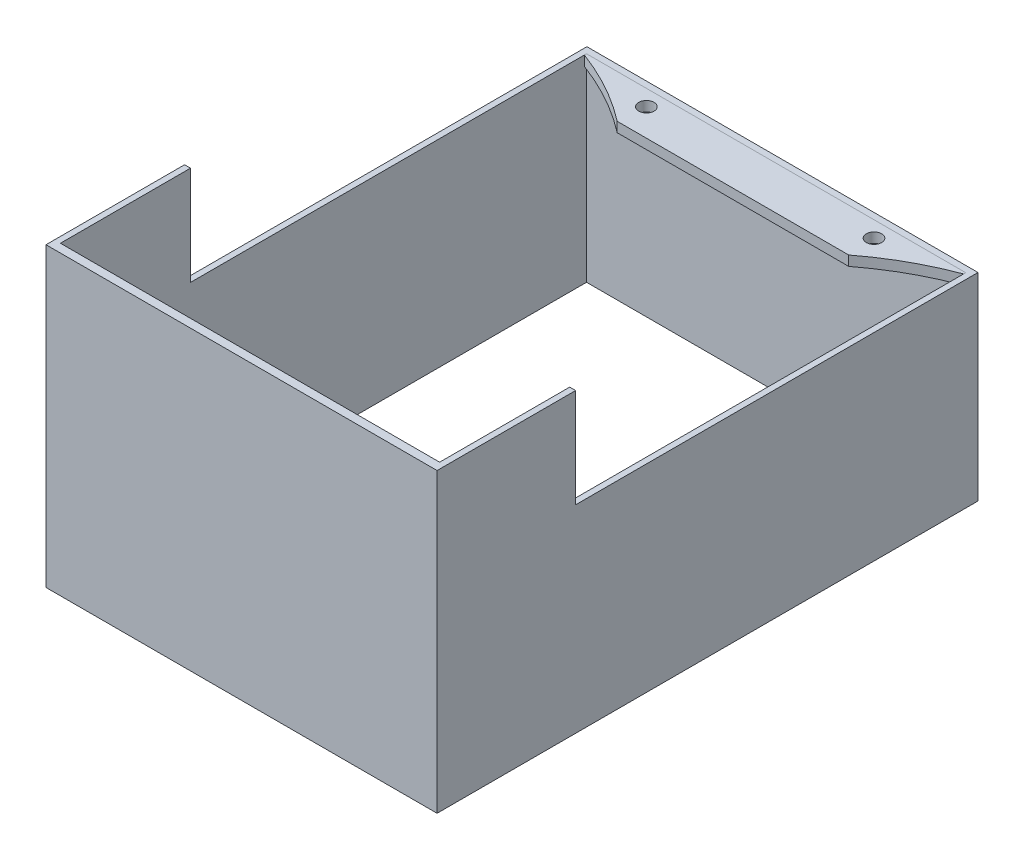
from build123d import *

# Parameters (mm, degrees)
SKETCH1_R           = 1.55
BOSS_EXTRUDE1_DEPTH = 2
BOSS_EXTRUDE2_START = 2
SKETCH1_5_W         = 10.82
SKETCH1_5_H         = 1.277782348
SKETCH1_5_W_2       = 55
SKETCH1_5_W_3       = 1.2
BOSS_EXTRUDE2_DEPTH = 10
BOSS_EXTRUDE3_START = -30
BOSS_EXTRUDE3_DEPTH = 20
SKETCH4_W           = 79.04
SKETCH4_H           = 109.322217652
SKETCH4_W_2         = 76.64
SKETCH4_H_2         = 106.329004974
BOSS_EXTRUDE4_DEPTH = 30


with BuildPart() as part:
    # Sketch1 → Boss-Extrude1 (new body)
    with BuildSketch(Plane(origin=(0, 0, 0), x_dir=(1, 0, 0), z_dir=(0, 1, 0))):
        with BuildLine():
            ThreePointArc((-38.32, 6.78955122), (-30.546525972, 3.20474118), (-23.39508053, -1.5))
            Line((-23.39508053, -1.5), (23.39508053, -1.5))
            ThreePointArc((23.39508053, -1.5), (30.546525972, 3.20474118), (38.32, 6.78955122))
            Line((38.32, 6.78955122), (38.32, 7.222217652))
            Line((38.32, 7.222217652), (-38.32, 7.222217652))
            Line((-38.32, 7.222217652), (-38.32, 6.78955122))
        make_face()
        with Locations((23, 4)):
            Circle(SKETCH1_R, mode=Mode.SUBTRACT)
        with Locations((-23, 4)):
            Circle(SKETCH1_R, mode=Mode.SUBTRACT)
    extrude(amount=BOSS_EXTRUDE1_DEPTH)


with BuildPart() as body_2:
    # Sketch1_5 → Boss-Extrude2 (new body)
    with BuildSketch(Plane(origin=(0, 0, 0), x_dir=(1, 0, 0), z_dir=(0, 1, 0)).offset(BOSS_EXTRUDE2_START)):
        with BuildLine():
            Line((35.171781926, -99.106787322), (-35.171781926, -99.106787322))
            ThreePointArc((-35.171781926, -99.106787322), (-37.328360588, -100.008937922), (-39.52, -100.822217652))
            Line((-39.52, -100.822217652), (39.52, -100.822217652))
            ThreePointArc((39.52, -100.822217652), (37.328360588, -100.008937922), (35.171781926, -99.106787322))
        make_face()
        with BuildLine():
            Line((-38.32, -99.106787322), (-38.32, 5.506787322))
            Line((-38.32, 5.506787322), (-38.32, 6.78955122))
            ThreePointArc((-38.32, 6.78955122), (-38.91879385, 7.009229691), (-39.52, 7.222217652))
            Line((-39.52, 7.222217652), (-39.52, -100.822217652))
            ThreePointArc((-39.52, -100.822217652), (-37.328360588, -100.008937922), (-35.171781926, -99.106787322))
            Line((-35.171781926, -99.106787322), (-38.32, -99.106787322))
        make_face()
        with BuildLine():
            Line((38.32, -99.106787322), (35.171781926, -99.106787322))
            ThreePointArc((35.171781926, -99.106787322), (37.328360588, -100.008937922), (39.52, -100.822217652))
            Line((39.52, -100.822217652), (39.52, 5.506787322))
            Line((39.52, 5.506787322), (38.32, 5.506787322))
            Line((38.32, 5.506787322), (38.32, -99.106787322))
        make_face()
        with Locations((-32.91, 7.861108826)):
            Rectangle(SKETCH1_5_W, SKETCH1_5_H)
        with Locations((0, 7.861108826)):
            Rectangle(SKETCH1_5_W_2, SKETCH1_5_H)
        with Locations((-38.92, 7.861108826)):
            Rectangle(SKETCH1_5_W_3, SKETCH1_5_H)
        with Locations((32.91, 7.861108826)):
            Rectangle(SKETCH1_5_W, SKETCH1_5_H)
        with Locations((38.92, 7.861108826)):
            Rectangle(SKETCH1_5_W_3, SKETCH1_5_H)
        with BuildLine():
            ThreePointArc((39.52, 7.222217652), (38.91879385, 7.009229691), (38.32, 6.78955122))
            Line((38.32, 6.78955122), (38.32, 5.506787322))
            Line((38.32, 5.506787322), (39.52, 5.506787322))
            Line((39.52, 5.506787322), (39.52, 7.222217652))
        make_face()
        with BuildLine():
            Line((39.52, 7.222217652), (38.32, 7.222217652))
            Line((38.32, 7.222217652), (38.32, 6.78955122))
            ThreePointArc((38.32, 6.78955122), (38.91879385, 7.009229691), (39.52, 7.222217652))
        make_face()
        with BuildLine():
            ThreePointArc((-39.52, 7.222217652), (-38.91879385, 7.009229691), (-38.32, 6.78955122))
            Line((-38.32, 6.78955122), (-38.32, 7.222217652))
            Line((-38.32, 7.222217652), (-39.52, 7.222217652))
        make_face()
    extrude(amount=-BOSS_EXTRUDE2_DEPTH)

    # Sketch3 → Boss-Extrude3 (add)
    with BuildSketch(Plane.XZ.offset(8).offset(BOSS_EXTRUDE3_START)):
        Polygon((-39.52, 100.822217652), (-39.52, 72.822217652), (-38.32, 72.822217652), (-38.32, 99.106787322), (38.32, 99.106787322), (38.32, 72.822217652), (39.52, 72.822217652), (39.52, 100.822217652), align=None)
    extrude(amount=BOSS_EXTRUDE3_DEPTH)

    # Sketch4 → Boss-Extrude4 (add)
    with BuildSketch(Plane.XZ.offset(8)):
        with Locations((0, 46.161108826)):
            Rectangle(SKETCH4_W, SKETCH4_H)
        with Locations((0, 45.942284835)):
            Rectangle(SKETCH4_W_2, SKETCH4_H_2, mode=Mode.SUBTRACT)
    extrude(amount=BOSS_EXTRUDE4_DEPTH)


solid = Compound([part.part, body_2.part])
